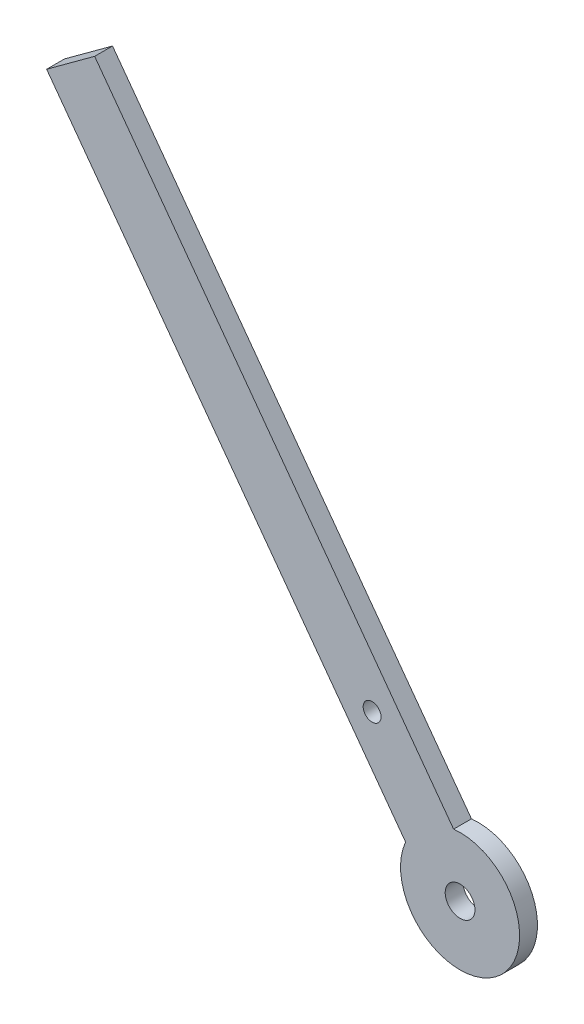
from build123d import *

# Parameters (mm, degrees)
SKETCH1_R           = 2.5
SKETCH1_R_2         = 1.500000002
BOSS_EXTRUDE1_DEPTH = 3


with BuildPart() as part:
    # Sketch1 → Boss-Extrude1 (new body)
    with BuildSketch(Plane.XY):
        with BuildLine():
            Line((-65.41272675, 89.25730784), (-69.445670133, 86.301742297))
            Line((-69.445670133, 86.301742297), (-9.152133067, 4.0296973))
            ThreePointArc((-9.152133067, 4.0296973), (5.911131085, -8.065886764), (-1.086246302, 9.940828385))
            Line((-1.086246302, 9.940828385), (-61.379783368, 92.212873382))
            Line((-61.379783368, 92.212873382), (-65.41272675, 89.25730784))
        make_face()
        Circle(SKETCH1_R, mode=Mode.SUBTRACT)
        with Locations((-14.777827712, 20.164716911)):
            Circle(SKETCH1_R_2, mode=Mode.SUBTRACT)
    extrude(amount=BOSS_EXTRUDE1_DEPTH)


solid = part.part
